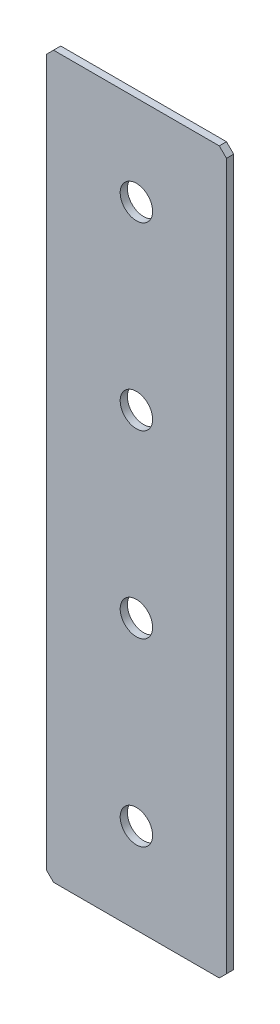
from build123d import *

# Parameters (mm, degrees)
SKETCH_1_W        = 50
SKETCH_1_H        = 200
EXTRUDE_1_DEPTH   = 2
CHAMFER_1_SIZE    = 2
HOLE_WIZARD_M81_D = 9


with BuildPart() as part:
    # Эскиз1 → Бобышка-Вытянуть1 (new body)
    with BuildSketch(Plane.XY):
        Rectangle(SKETCH_1_W, SKETCH_1_H)
    extrude(amount=EXTRUDE_1_DEPTH)

    # Фаска1
    chamfer_1_edges = [part.edges().sort_by_distance(p)[0] for p in [
        (25, -100, 1),
        (-25, -100, 1),
        (-25, 100, 1),
        (25, 100, 1),
    ]]
    chamfer(chamfer_1_edges, length=CHAMFER_1_SIZE)

    # Отверстие с зазором M81 (through all)
    with Locations(Plane.XY.offset(2)):
        with Locations((0, 75), (0, 25), (0, -25), (0, -75)):
            Hole(HOLE_WIZARD_M81_D / 2)


solid = part.part
